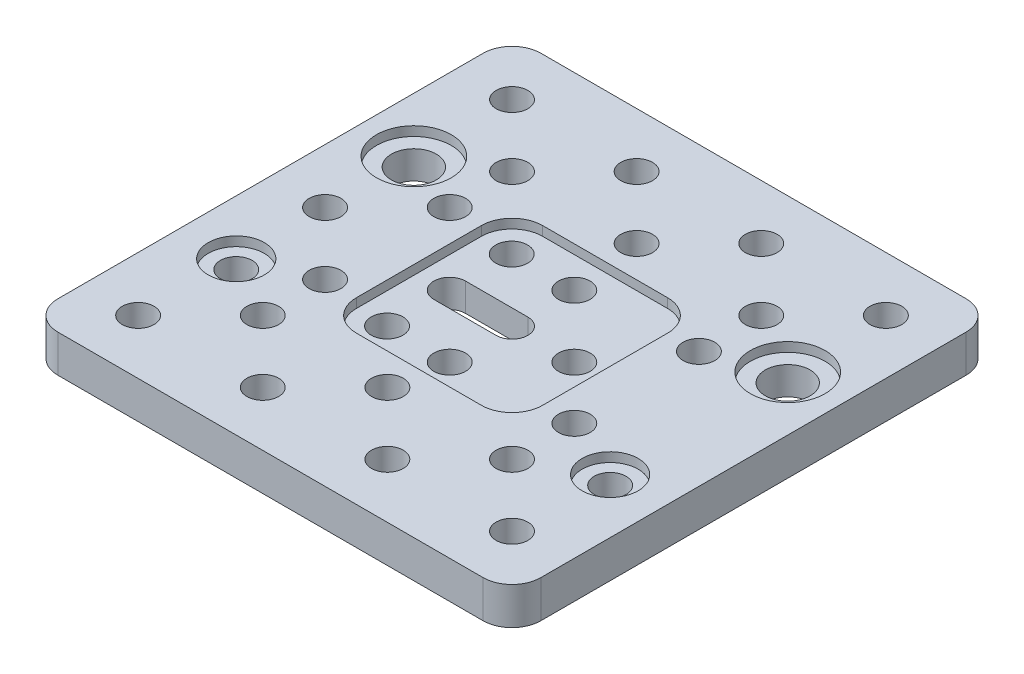
from build123d import *

# Parameters (mm, degrees)
SKETCH1_R           = 2.55
SKETCH1_R_2         = 3.6
BOSS_EXTRUDE1_DEPTH = 6
SKETCH2_R           = 6
SKETCH2_R_2         = 4.5
CUT_EXTRUDE1_DEPTH  = 1.5


with BuildPart() as part:
    # Sketch1 → Boss-Extrude1 (new body)
    with BuildSketch(Plane(origin=(0, 0, 0), x_dir=(1, 0, 0), z_dir=(0, 1, 0))):
        with BuildLine():
            Line((-34.12, 0), (34.12, 0))
            ThreePointArc((34.12, 0), (37.397439931, 1.357560069), (38.755, 4.635))
            Line((38.755, 4.635), (38.755, 72.884))
            ThreePointArc((38.755, 72.884), (37.397439931, 76.161439931), (34.12, 77.519))
            Line((34.12, 77.519), (-34.12, 77.519))
            ThreePointArc((-34.12, 77.519), (-37.397439931, 76.161439931), (-38.755, 72.884))
            Line((-38.755, 72.884), (-38.755, 4.635))
            ThreePointArc((-38.755, 4.635), (-37.397439931, 1.357560069), (-34.12, 0))
        make_face()
        with Locations((-10, 68.76)):
            Circle(SKETCH1_R, mode=Mode.SUBTRACT)
        with Locations((-30, 68.76)):
            Circle(SKETCH1_R, mode=Mode.SUBTRACT)
        with Locations((10, 68.76)):
            Circle(SKETCH1_R, mode=Mode.SUBTRACT)
        with Locations((30, 68.76)):
            Circle(SKETCH1_R, mode=Mode.SUBTRACT)
        with Locations((-30, 8.759)):
            Circle(SKETCH1_R, mode=Mode.SUBTRACT)
        with Locations((-10, 8.759)):
            Circle(SKETCH1_R, mode=Mode.SUBTRACT)
        with Locations((10, 8.759)):
            Circle(SKETCH1_R, mode=Mode.SUBTRACT)
        with Locations((30, 8.759)):
            Circle(SKETCH1_R, mode=Mode.SUBTRACT)
        with Locations((0, 58.76)):
            Circle(SKETCH1_R, mode=Mode.SUBTRACT)
        with Locations((-20, 58.76)):
            Circle(SKETCH1_R, mode=Mode.SUBTRACT)
        with Locations((20, 58.76)):
            Circle(SKETCH1_R, mode=Mode.SUBTRACT)
        with Locations((20, 18.759)):
            Circle(SKETCH1_R, mode=Mode.SUBTRACT)
        with Locations((0, 18.759)):
            Circle(SKETCH1_R, mode=Mode.SUBTRACT)
        with Locations((-20, 18.759)):
            Circle(SKETCH1_R, mode=Mode.SUBTRACT)
        with Locations((-20, 48.7595)):
            Circle(SKETCH1_R, mode=Mode.SUBTRACT)
        with Locations((0, 48.7595)):
            Circle(SKETCH1_R, mode=Mode.SUBTRACT)
        with Locations((20, 48.7595)):
            Circle(SKETCH1_R, mode=Mode.SUBTRACT)
        with Locations((-10.05, 48.7595)):
            Circle(SKETCH1_R, mode=Mode.SUBTRACT)
        with Locations((20, 28.7595)):
            Circle(SKETCH1_R, mode=Mode.SUBTRACT)
        with Locations((0, 28.7595)):
            Circle(SKETCH1_R, mode=Mode.SUBTRACT)
        with Locations((-10.05, 28.7595)):
            Circle(SKETCH1_R, mode=Mode.SUBTRACT)
        with Locations((-20, 28.7595)):
            Circle(SKETCH1_R, mode=Mode.SUBTRACT)
        with Locations((10, 38.7595)):
            Circle(SKETCH1_R, mode=Mode.SUBTRACT)
        with Locations((-30, 38.7595)):
            Circle(SKETCH1_R, mode=Mode.SUBTRACT)
        with Locations((-30, 53.01)):
            Circle(SKETCH1_R_2, mode=Mode.SUBTRACT)
        with Locations((-30, 24.509)):
            Circle(SKETCH1_R, mode=Mode.SUBTRACT)
        with Locations((30, 24.509)):
            Circle(SKETCH1_R, mode=Mode.SUBTRACT)
        with Locations((30, 53.01)):
            Circle(SKETCH1_R_2, mode=Mode.SUBTRACT)
        with BuildLine():
            Line((0, 36.2095), (-10, 36.2095))
            ThreePointArc((-10, 36.2095), (-12.55, 38.7595), (-10, 41.3095))
            Line((-10, 41.3095), (0, 41.3095))
            ThreePointArc((0, 41.3095), (2.55, 38.7595), (0, 36.2095))
        make_face(mode=Mode.SUBTRACT)
    extrude(amount=BOSS_EXTRUDE1_DEPTH)

    # Sketch2 → Cut-Extrude1 (cut)
    with BuildSketch(Plane(origin=(0, 6, 0), x_dir=(1, 0, 0), z_dir=(0, 1, 0))):
        with Locations((-30, 53.01)):
            Circle(SKETCH2_R)
        with Locations((-30, 24.509)):
            Circle(SKETCH2_R_2)
        with Locations((30, 53.01)):
            Circle(SKETCH2_R)
        with Locations((30, 24.509)):
            Circle(SKETCH2_R_2)
        with BuildLine():
            Line((-10.03, 53.7095), (10.03, 53.7095))
            ThreePointArc((10.03, 53.7095), (13.50967247, 52.26817247), (14.951, 48.7885))
            Line((14.951, 48.7885), (14.951, 28.7305))
            ThreePointArc((14.951, 28.7305), (13.50967247, 25.25082753), (10.03, 23.8095))
            Line((10.03, 23.8095), (-10.03, 23.8095))
            ThreePointArc((-10.03, 23.8095), (-13.50967247, 25.25082753), (-14.951, 28.7305))
            Line((-14.951, 28.7305), (-14.951, 48.7885))
            ThreePointArc((-14.951, 48.7885), (-13.50967247, 52.26817247), (-10.03, 53.7095))
        make_face()
    extrude(amount=-CUT_EXTRUDE1_DEPTH, mode=Mode.SUBTRACT)


solid = part.part
